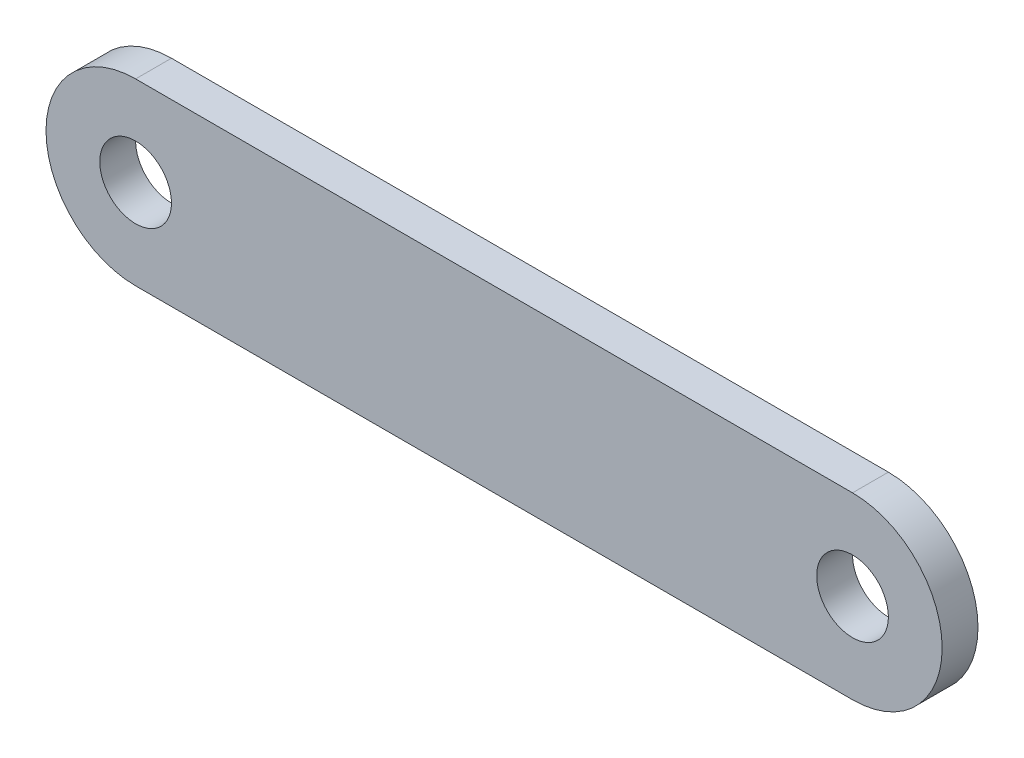
from build123d import *

# Parameters (mm, degrees)
EXTRUDE_2_DEPTH     = 10
SKETCH_2_R          = 10
CUT_EXTRUDE_2_DEPTH = 10


with BuildPart() as part:
    # Эскиз1 → Бобышка-Вытянуть2 (new body)
    with BuildSketch(Plane.XY):
        with BuildLine():
            Line((0, 25), (200, 25))
            ThreePointArc((200, 25), (225, 0), (200, -25))
            Line((200, -25), (0, -25))
            ThreePointArc((0, -25), (-25, 0), (0, 25))
        make_face()
    extrude(amount=EXTRUDE_2_DEPTH)

    # Эскиз2 → Вырез-Вытянуть2 (cut)
    with BuildSketch(Plane.XY.offset(10)):
        Circle(SKETCH_2_R)
        with Locations((200, 0)):
            Circle(SKETCH_2_R)
    extrude(amount=-CUT_EXTRUDE_2_DEPTH, mode=Mode.SUBTRACT)


solid = part.part
